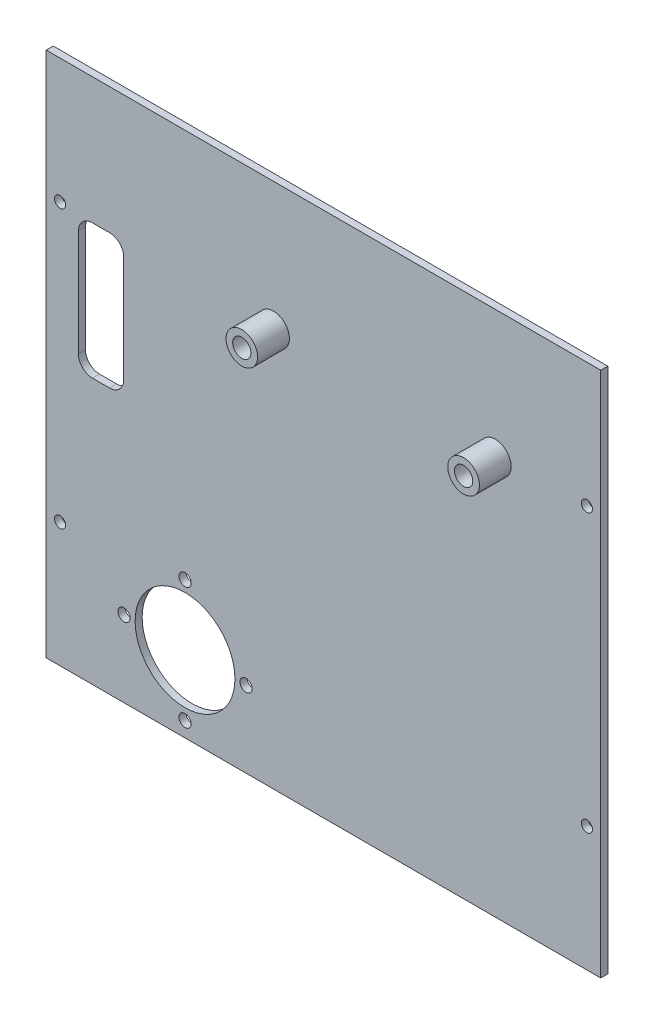
from build123d import *

# Parameters (mm, degrees)
SKETCH1_W             = 100
SKETCH1_H             = 94.92
BOSS_EXTRUDE1_DEPTH   = 1.27
SKETCH8_R             = 2.85
SKETCH8_R_2           = 2
BOSS_EXTRUDE3_DEPTH   = 7
M4X0_7_TAPPED_HOLE1_D = 3.3
SKETCH13_R            = 9
SKETCH13_R_2          = 1.1
CUT_EXTRUDE7_DEPTH    = 5
SKETCH14_R            = 1
CUT_EXTRUDE8_DEPTH    = 10
CUT_EXTRUDE9_DEPTH    = 2.54


with BuildPart() as part:
    # Sketch1 → Boss-Extrude1 (new body)
    with BuildSketch(Plane.XY):
        with Locations((50, 48.73)):
            Rectangle(SKETCH1_W, SKETCH1_H)
    extrude(amount=BOSS_EXTRUDE1_DEPTH)

    # Sketch8 → Boss-Extrude3 (add)
    with BuildSketch(Plane(origin=(0, 0, 0), x_dir=(-1, 0, 0), z_dir=(0, 0, -1))):
        with Locations((-81.00001, 73.05481987)):
            Circle(SKETCH8_R)
        with Locations((-81.00001, 73.05481987)):
            Circle(SKETCH8_R_2, mode=Mode.SUBTRACT)
        with Locations((-81.00001, 73.05481987)):
            Circle(SKETCH8_R_2)
        with Locations((-41.00001, 73.05481987)):
            Circle(SKETCH8_R)
        with Locations((-41.00001, 73.05481987)):
            Circle(SKETCH8_R_2, mode=Mode.SUBTRACT)
        with Locations((-41.00001, 73.05481987)):
            Circle(SKETCH8_R_2)
    extrude(amount=-BOSS_EXTRUDE3_DEPTH)

    # M4x0.7 Tapped Hole1 (through all)
    with Locations(Plane.XY.offset(7)):
        with Locations((81.00001, 73.05481987), (41.00001, 73.05481987)):
            Hole(M4X0_7_TAPPED_HOLE1_D / 2)

    # Sketch13 → Cut-Extrude7 (cut)
    with BuildSketch(Plane(origin=(0, 0, 0), x_dir=(-1, 0, 0), z_dir=(0, 0, -1))):
        with Locations((-25.031645402, 15)):
            Circle(SKETCH13_R)
        with Locations((-14.031645402, 15)):
            Circle(SKETCH13_R_2)
        with Locations((-25.031645402, 4)):
            Circle(SKETCH13_R_2)
        with Locations((-36.031645402, 15)):
            Circle(SKETCH13_R_2)
        with Locations((-25.031645402, 26)):
            Circle(SKETCH13_R_2)
    extrude(amount=-CUT_EXTRUDE7_DEPTH, mode=Mode.SUBTRACT)

    # Sketch14 → Cut-Extrude8 (cut)
    with BuildSketch(Plane(origin=(0, 0, 0), x_dir=(-1, 0, 0), z_dir=(0, 0, -1))):
        with Locations(Location((-2.5, 73.73, 0), (0, 0, 180))):
            Circle(SKETCH14_R)
        with Locations(Location((-2.5, 23.73, 0), (0, 0, 180))):
            Circle(SKETCH14_R)
        with Locations((-97.5, 23.73)):
            Circle(SKETCH14_R)
        with Locations((-97.5, 73.73)):
            Circle(SKETCH14_R)
    extrude(amount=-CUT_EXTRUDE8_DEPTH, mode=Mode.SUBTRACT)

    # Sketch15 → Cut-Extrude9 (cut)
    with BuildSketch(Plane.XY.offset(1.27)):
        with BuildLine():
            Line((5.801106051, 51.665736829), (5.801106051, 70.837304612))
            ThreePointArc((5.801106051, 70.837304612), (6.545054826, 72.633355836), (8.341106051, 73.377304612))
            Line((8.341106051, 73.377304612), (11.435588088, 73.377304612))
            ThreePointArc((11.435588088, 73.377304612), (13.231639313, 72.633355836), (13.975588088, 70.837304612))
            Line((13.975588088, 70.837304612), (13.975588088, 51.665736829))
            ThreePointArc((13.975588088, 51.665736829), (13.231639313, 49.869685605), (11.435588088, 49.125736829))
            Line((11.435588088, 49.125736829), (8.341106051, 49.125736829))
            ThreePointArc((8.341106051, 49.125736829), (6.545054826, 49.869685605), (5.801106051, 51.665736829))
        make_face()
    extrude(amount=-CUT_EXTRUDE9_DEPTH, mode=Mode.SUBTRACT)


solid = part.part
